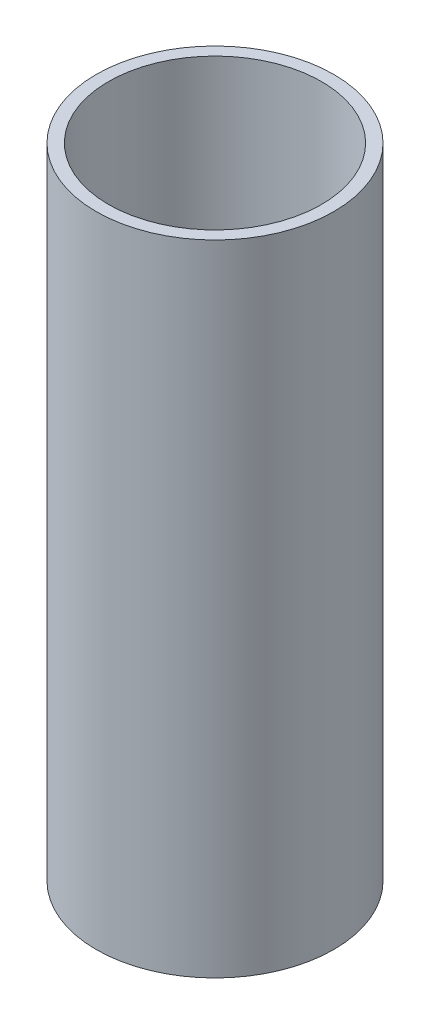
from build123d import *

# Parameters (mm, degrees)
SKETCH1_R           = 56.6674
SKETCH1_R_2         = 50.8
EXTRUDE_THIN1_DEPTH = 304.8


with BuildPart() as part:
    # Sketch1 → Extrude-Thin1 (new body)
    with BuildSketch(Plane(origin=(0, 0, 0), x_dir=(1, 0, 0), z_dir=(0, 1, 0))):
        Circle(SKETCH1_R)
        Circle(SKETCH1_R_2, mode=Mode.SUBTRACT)
    extrude(amount=EXTRUDE_THIN1_DEPTH)


solid = part.part
